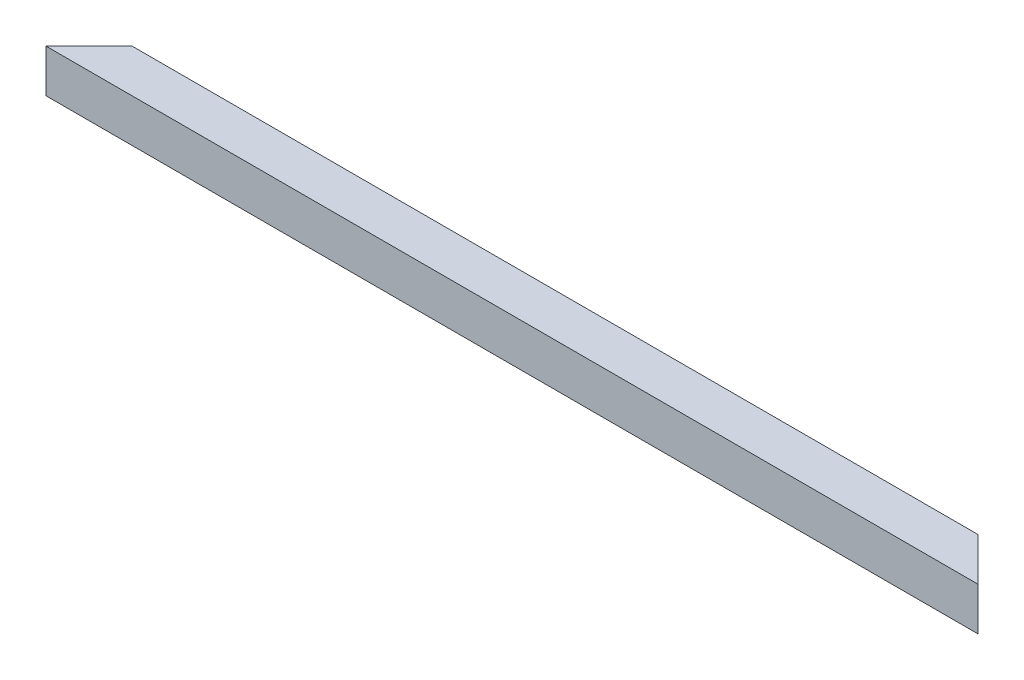
from build123d import *

# Parameters (mm, degrees)
SKETCH1_W           = 550
SKETCH1_H           = 25.4
BOSS_EXTRUDE1_DEPTH = 25.4
SKETCH2_W           = 23
SKETCH2_H           = 23
CUT_EXTRUDE1_DEPTH  = 550
CUT_EXTRUDE2_DEPTH  = 25.4


with BuildPart() as part:
    # Sketch1 → Boss-Extrude1 (new body)
    with BuildSketch(Plane(origin=(0, 0, 0), x_dir=(1, 0, 0), z_dir=(0, 1, 0))):
        with Locations((275, 12.7)):
            Rectangle(SKETCH1_W, SKETCH1_H)
    extrude(amount=BOSS_EXTRUDE1_DEPTH)

    # Sketch2 → Cut-Extrude1 (cut)
    with BuildSketch(Plane(origin=(550, 0, 0), x_dir=(0, 0, -1), z_dir=(1, 0, 0))):
        with Locations((12.7, 12.7)):
            Rectangle(SKETCH2_W, SKETCH2_H)
    extrude(amount=-CUT_EXTRUDE1_DEPTH, mode=Mode.SUBTRACT)

    # Sketch3 → Cut-Extrude2 (cut)
    with BuildSketch(Plane(origin=(0, 25.4, 0), x_dir=(1, 0, 0), z_dir=(0, 1, 0))):
        Polygon((0, 0), (25.4, 25.4), (0, 25.4), align=None)
        Polygon((550, 0), (524.6, 25.4), (550, 25.4), align=None)
    extrude(amount=-CUT_EXTRUDE2_DEPTH, mode=Mode.SUBTRACT)


solid = part.part
